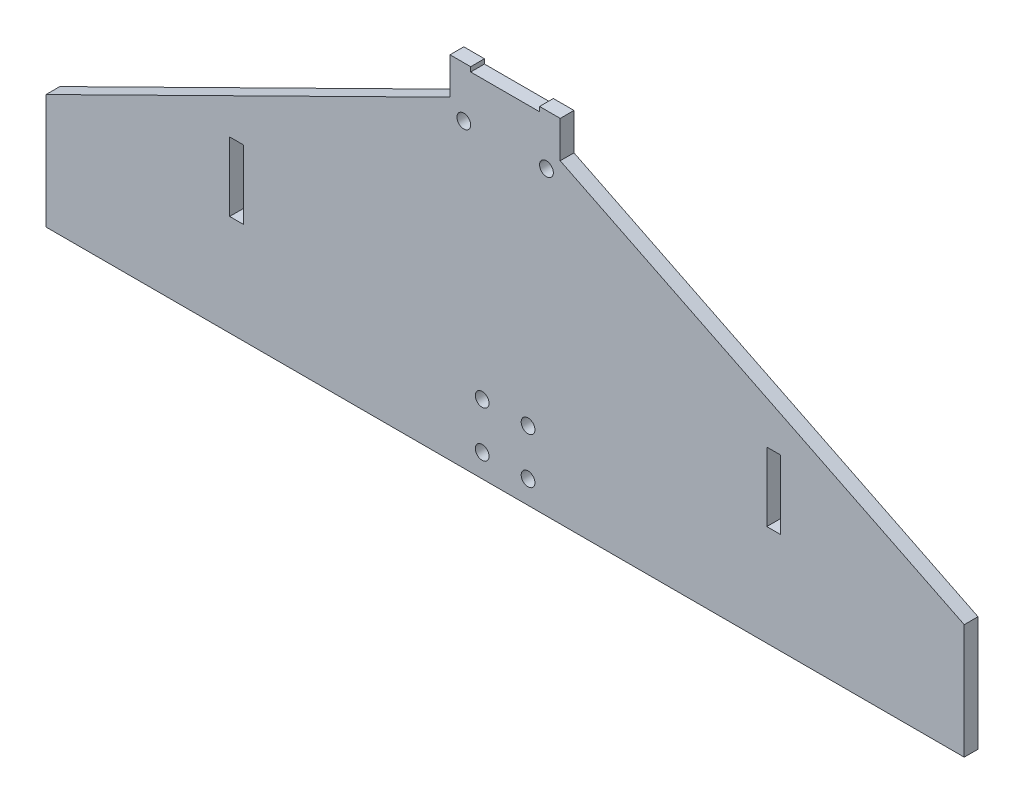
from build123d import *

# Parameters (mm, degrees)
EXTRUDE_1_DEPTH     = 3
SKETCH_4_R          = 1.5
CUT_EXTRUDE_2_DEPTH = 5
SKETCH_6_R          = 1.5
CUT_EXTRUDE_4_DEPTH = 5
SKETCH_7_W          = 3
SKETCH_7_H          = 15
CUT_EXTRUDE_5_DEPTH = 10


with BuildPart() as part:
    # 草图2 → 凸台-拉伸1 (new body)
    with BuildSketch(Plane.XY):
        Polygon((-7.5, 56.5), (-7.5, 55.5), (7.5, 55.5), (7.5, 56.5), (12, 56.5), (12, 48.5), (100, 5), (100, -20), (-100, -20), (-100, 5), (-12, 48.5), (-12, 56.5), align=None)
    extrude(amount=EXTRUDE_1_DEPTH)

    # 草图4 → 切除-拉伸2 (cut)
    with BuildSketch(Plane.XY.offset(3)):
        with Locations((-5, -5)):
            Circle(SKETCH_4_R)
        with Locations((5, -5)):
            Circle(SKETCH_4_R)
        with Locations((-5, -15)):
            Circle(SKETCH_4_R)
        with Locations((5, -15)):
            Circle(SKETCH_4_R)
    extrude(amount=-CUT_EXTRUDE_2_DEPTH, mode=Mode.SUBTRACT)

    # 草图6 → 切除-拉伸4 (cut)
    with BuildSketch(Plane.XY.offset(3)):
        with Locations((-9, 45.5)):
            Circle(SKETCH_6_R)
        with Locations((9, 45.5)):
            Circle(SKETCH_6_R)
    extrude(amount=-CUT_EXTRUDE_4_DEPTH, mode=Mode.SUBTRACT)

    # 草图7 → 切除-拉伸5 (cut)
    with BuildSketch(Plane.XY.offset(3)):
        with Locations((-58.5, 9.5)):
            Rectangle(SKETCH_7_W, SKETCH_7_H)
        with Locations((58.5, 9.5)):
            Rectangle(SKETCH_7_W, SKETCH_7_H)
    extrude(amount=-CUT_EXTRUDE_5_DEPTH, mode=Mode.SUBTRACT)


solid = part.part
